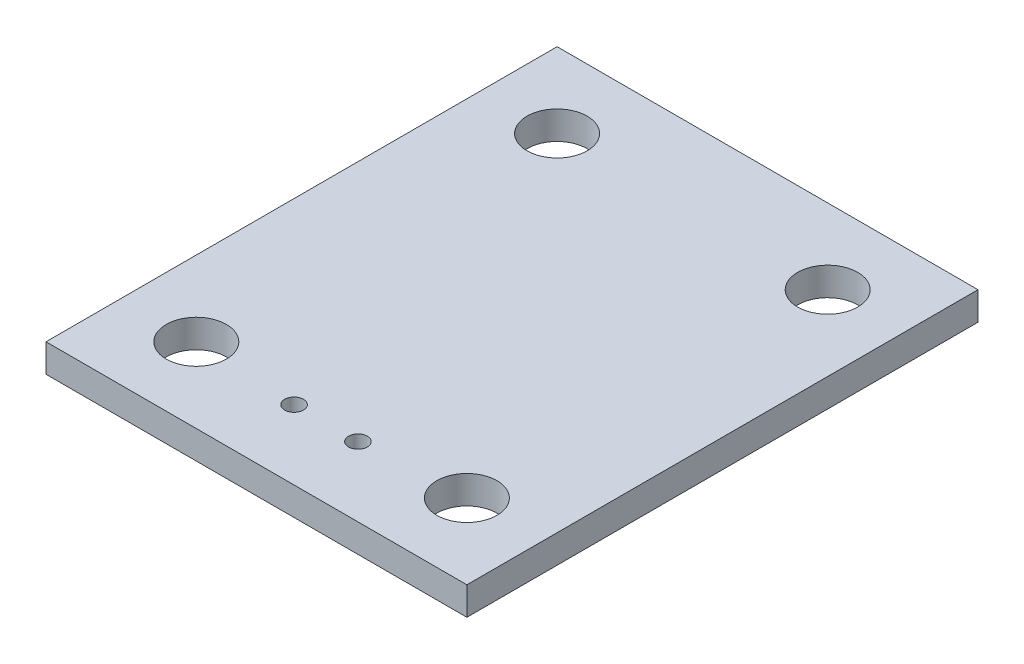
from build123d import *

# Parameters (mm, degrees)
SKETCH1_W           = 22.4
SKETCH1_H           = 27.2
SKETCH1_R           = 1.6
SKETCH1_R_2         = 0.5
BOSS_EXTRUDE1_DEPTH = 1.5


with BuildPart() as part:
    # Sketch1 → Boss-Extrude1 (new body)
    with BuildSketch(Plane(origin=(0, 0, 0), x_dir=(1, 0, 0), z_dir=(0, 1, 0))):
        Rectangle(SKETCH1_W, SKETCH1_H)
        with Locations((7.2, 9.6)):
            Circle(SKETCH1_R, mode=Mode.SUBTRACT)
        with Locations((-7.2, 9.6)):
            Circle(SKETCH1_R, mode=Mode.SUBTRACT)
        with Locations((-7.2, -9.6)):
            Circle(SKETCH1_R, mode=Mode.SUBTRACT)
        with Locations((-1.7, -9.9)):
            Circle(SKETCH1_R_2, mode=Mode.SUBTRACT)
        with Locations((1.7, -9.9)):
            Circle(SKETCH1_R_2, mode=Mode.SUBTRACT)
        with Locations((7.2, -9.6)):
            Circle(SKETCH1_R, mode=Mode.SUBTRACT)
    extrude(amount=-BOSS_EXTRUDE1_DEPTH)


solid = part.part
